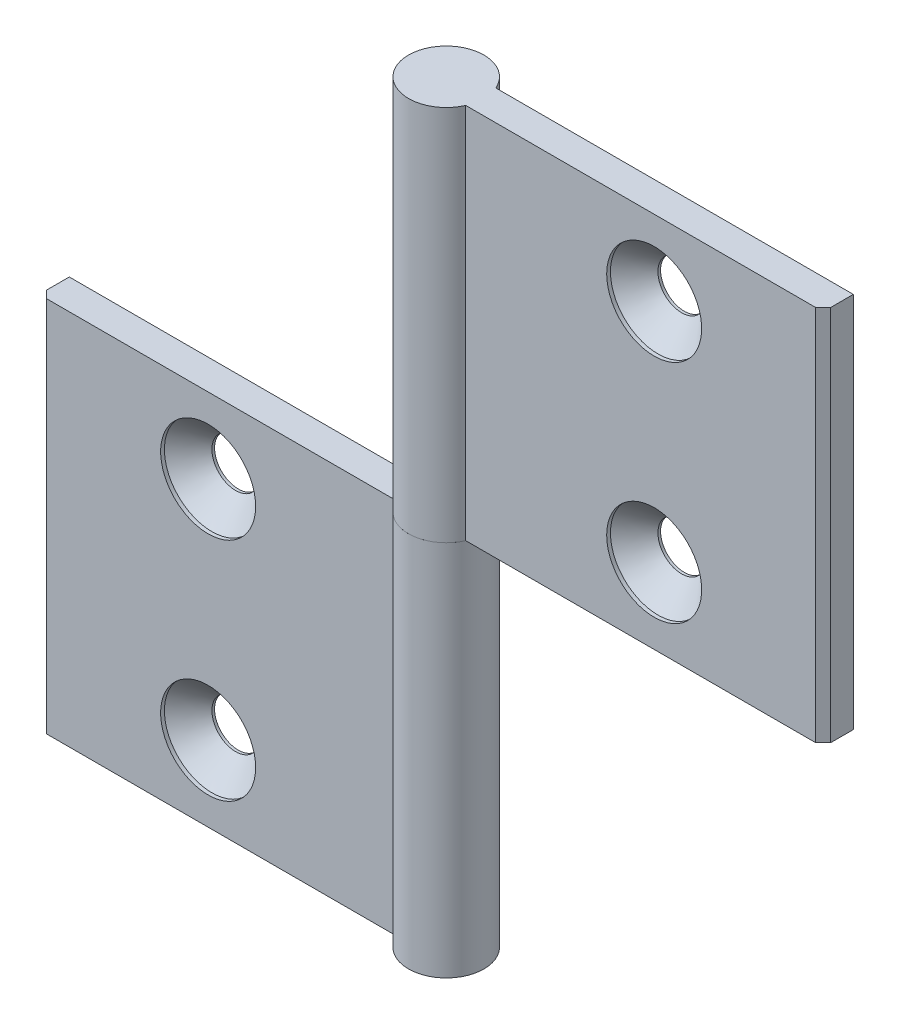
from build123d import *

# Parameters (mm, degrees)
EXTRUDE_1_DEPTH            = 25
HOLE_WIZARD_M61_AT_2_COUNT = 2
HOLE_WIZARD_M61_AT_2_PITCH = 30
PATTERN_CIRCULAR_1_COUNT   = 2


with BuildPart() as part:
    # Эскиз1 → Бобышка-Вытянуть1 (new body, symmetric)
    with BuildSketch(Plane(origin=(0, 0, 0), x_dir=(1, 0, 0), z_dir=(0, 1, 0))):
        with BuildLine():
            Line((-4.582575695, 2), (-52, 2))
            Line((-52, 2), (-52, -1))
            Line((-52, -1), (-51, -2))
            Line((-51, -2), (-4.582575695, -2))
            ThreePointArc((-4.582575695, -2), (5, 0), (-4.582575695, 2))
        make_face()
    extrude(amount=EXTRUDE_1_DEPTH, both=True)

    # Эскиз6 → Зенковка для винта с полупотайной головкой M61 (revolve, cut)
    with BuildSketch(Plane(origin=(-29.582575695, 15, 2), x_dir=(0, -1, 0), z_dir=(1, 0, 0))):
        Polygon((0, 0), (0, 7), (3.15, 7), (3.15, 3.65), (6.3, 0.5), (6.3, 0), align=None)
    hole_wizard_m61 = revolve(axis=Axis((-29.582575695, 15, 8.35), (0, 0, -1)), mode=Mode.SUBTRACT)

    # Зенковка для винта с полупотайной головкой M61 at 2: Зенковка для винта с полупотайной головкой M61 ×2
    with Locations(*[(0, -i * HOLE_WIZARD_M61_AT_2_PITCH, 0) for i in range(1, HOLE_WIZARD_M61_AT_2_COUNT)]):
        add(hole_wizard_m61, mode=Mode.SUBTRACT)


with BuildPart() as pattern_circular_1_1:
    # Круговой массив1: pattern copy
    add(part.part.rotate(Axis((0, 25, 0), (0, 0, 1)), 1 * 360 / PATTERN_CIRCULAR_1_COUNT))


solid = Compound([part.part, pattern_circular_1_1.part])
